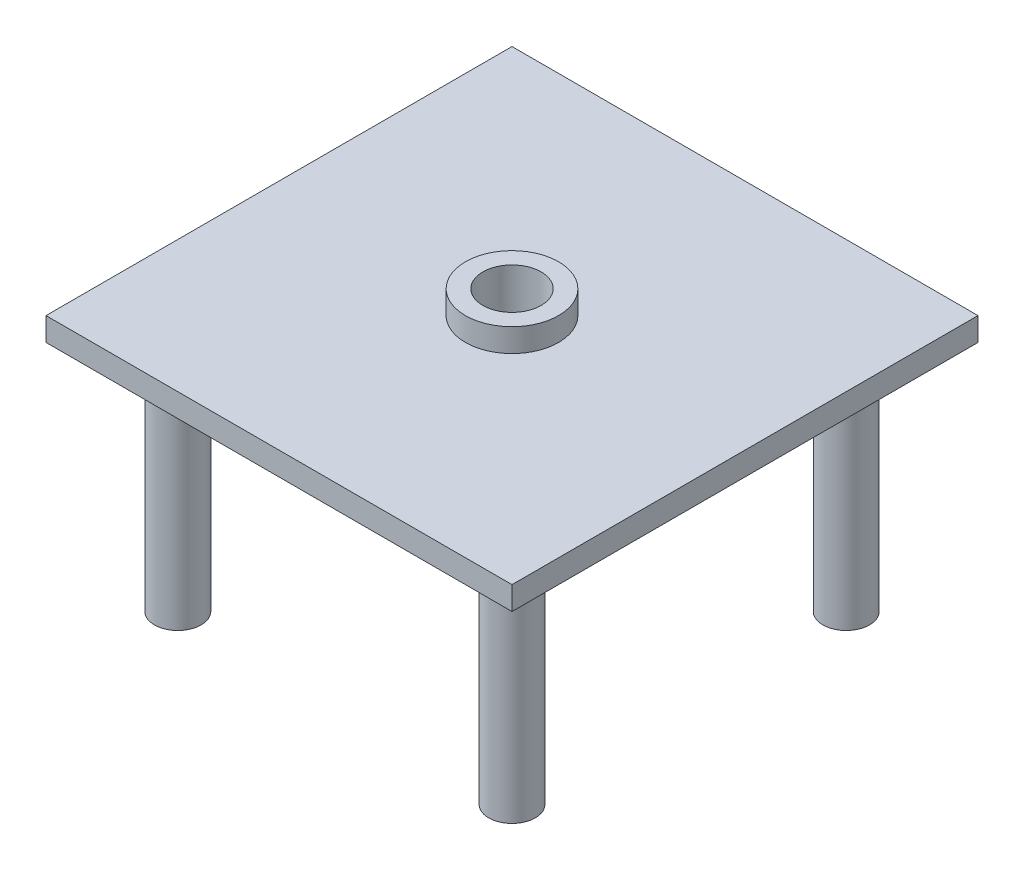
from build123d import *

# Parameters (mm, degrees)
SKETCH1_R             = 20
BOSS_EXTRUDE1_DEPTH   = 200
BOSS_EXTRUDE1_2_DEPTH = 200
BOSS_EXTRUDE1_3_DEPTH = 200
BOSS_EXTRUDE1_4_DEPTH = 200
SKETCH2_W             = 400
SKETCH2_H             = 400
SKETCH2_R             = 25
BOSS_EXTRUDE2_DEPTH   = 20
SKETCH3_R             = 40
SKETCH3_R_2           = 25
BOSS_EXTRUDE3_DEPTH   = 20


with BuildPart() as part:
    # Sketch1 → Boss-Extrude1 (new body)
    with BuildSketch(Plane(origin=(0, 0, 0), x_dir=(1, 0, 0), z_dir=(0, 1, 0))):
        with Locations((-143.431457505, 143.431457505)):
            Circle(SKETCH1_R)
    extrude(amount=BOSS_EXTRUDE1_DEPTH)



with BuildPart() as body_2:
    # Sketch1 → Boss-Extrude1 2 (new body)
    with BuildSketch(Plane(origin=(0, 0, 0), x_dir=(1, 0, 0), z_dir=(0, 1, 0))):
        with Locations((-143.431457505, -143.431457505)):
            Circle(SKETCH1_R)
    extrude(amount=BOSS_EXTRUDE1_2_DEPTH)


with BuildPart() as body_3:
    # Sketch1 → Boss-Extrude1 3 (new body)
    with BuildSketch(Plane(origin=(0, 0, 0), x_dir=(1, 0, 0), z_dir=(0, 1, 0))):
        with Locations((143.431457505, -143.431457505)):
            Circle(SKETCH1_R)
    extrude(amount=BOSS_EXTRUDE1_3_DEPTH)


with BuildPart() as body_4:
    # Sketch1 → Boss-Extrude1 4 (new body)
    with BuildSketch(Plane(origin=(0, 0, 0), x_dir=(1, 0, 0), z_dir=(0, 1, 0))):
        with Locations((143.431457505, 143.431457505)):
            Circle(SKETCH1_R)
    extrude(amount=BOSS_EXTRUDE1_4_DEPTH)


with BuildPart() as part_1:
    add(part.part)

    add(body_2.part)  # Boss-Extrude2 merges body 2

    add(body_3.part)  # Boss-Extrude2 merges body 3

    add(body_4.part)  # Boss-Extrude2 merges body 4
    # Sketch2 → Boss-Extrude2 (add)
    with BuildSketch(Plane(origin=(0, 200, 0), x_dir=(1, 0, 0), z_dir=(0, 1, 0))):
        Rectangle(SKETCH2_W, SKETCH2_H)
        Circle(SKETCH2_R, mode=Mode.SUBTRACT)
    extrude(amount=BOSS_EXTRUDE2_DEPTH)

    # Sketch3 → Boss-Extrude3 (add)
    with BuildSketch(Plane(origin=(0, 220, 0), x_dir=(1, 0, 0), z_dir=(0, 1, 0))):
        Circle(SKETCH3_R)
        Circle(SKETCH3_R_2, mode=Mode.SUBTRACT)
    extrude(amount=BOSS_EXTRUDE3_DEPTH)


solid = part_1.part
